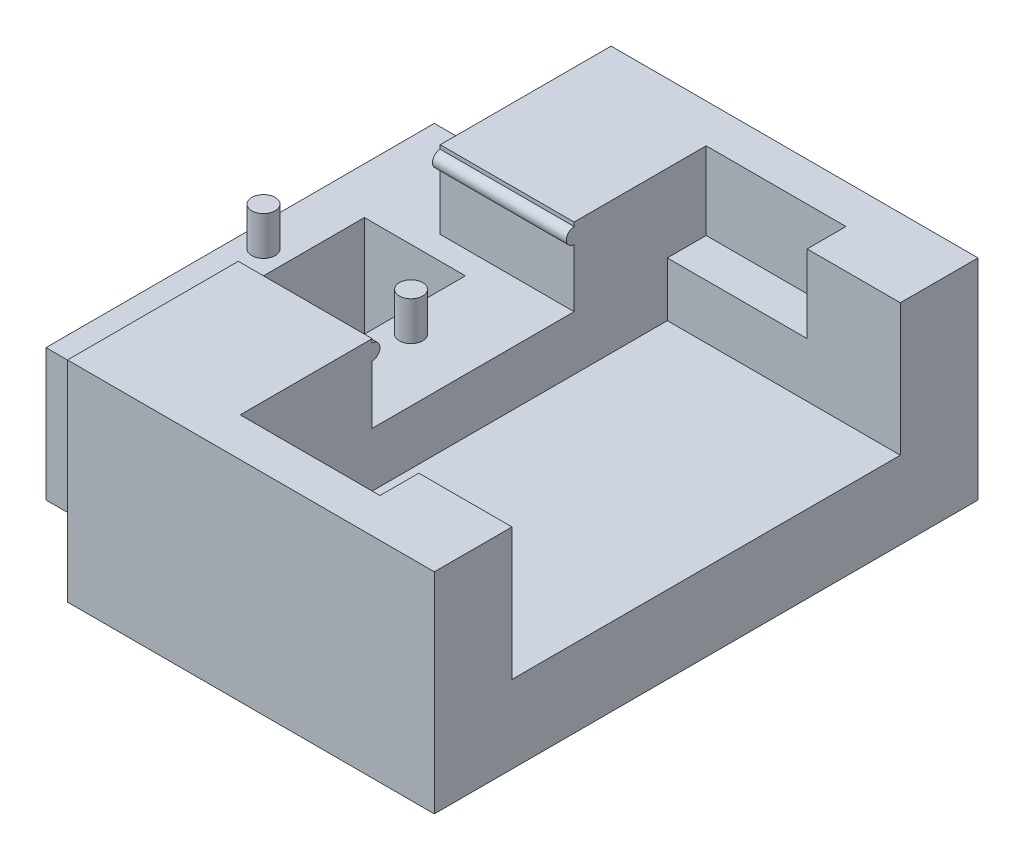
from build123d import *

# Parameters (mm, degrees)
SKETCH1_W             = 15.24
SKETCH1_H             = 12.7
MAIN_BASE_DEPTH       = 2.54
ALIGNMENTPINS_START   = 1.778
SKETCH2_R             = 0.381
ALIGNMENTPINS_DEPTH   = 1.27
ALIGNMENTPINS_2_DEPTH = 1.27
SKETCH7_W             = 7.62
SKETCH7_H             = 12.7
PCBOARDEDGES_DEPTH    = 1.778
SKETCH12_W            = 4.379010271
SKETCH12_H            = 3.048
CONNECTORALIGN_DEPTH  = 2.54
SKETCH13_W            = 3.302
SKETCH13_H            = 5.08
LEDHOLE_DEPTH         = 5.318
SKETCH14_W            = 11.999010271
SKETCH14_H            = 6.858
SHOULDER_DEPTH        = 2.54
SKETCH15_W            = 11.999010271
SKETCH15_H            = 6.858
SHOULDER2_DEPTH       = 2.54
PCB_CLIP_START        = -4.37901
SKETCH17_R            = 0.254
PCB_CLIP_DEPTH        = 4.37901
SKETCH18_W            = 4.572
SKETCH18_H            = 2.54
NUNCHUCKCLIP_DEPTH    = 1.27
SKETCH19_W            = 4.572
SKETCH19_H            = 2.54
NUNCHUCKCLIP2_DEPTH   = 1.27
CUT_EXTRUDE1_DEPTH    = 0.508


with BuildPart() as part:
    # Sketch1 → Main Base (new body)
    with BuildSketch(Plane(origin=(0, 0, 0), x_dir=(1, 0, 0), z_dir=(0, 1, 0))):
        with Locations((7.62, 6.35)):
            Rectangle(SKETCH1_W, SKETCH1_H)
    extrude(amount=MAIN_BASE_DEPTH)



with BuildPart() as body_2:
    # Sketch2 → AlignmentPins (new body)
    with BuildSketch(Plane(origin=(0, 2.54, 0), x_dir=(-1, 0, 0), z_dir=(0, 1, 0)).offset(ALIGNMENTPINS_START)):
        with Locations((-0.762, -6.35)):
            Circle(SKETCH2_R)
    extrude(amount=ALIGNMENTPINS_DEPTH)


with BuildPart() as body_3:
    # Sketch2 → AlignmentPins 2 (new body)
    with BuildSketch(Plane(origin=(0, 2.54, 0), x_dir=(-1, 0, 0), z_dir=(0, 1, 0)).offset(ALIGNMENTPINS_START)):
        with Locations((-5.588, -6.35)):
            Circle(SKETCH2_R)
    extrude(amount=ALIGNMENTPINS_2_DEPTH)


with BuildPart() as part_1:
    add(part.part)

    add(body_2.part)  # PCBoardEdges merges body 2

    add(body_3.part)  # PCBoardEdges merges body 3
    # Sketch7 → PCBoardEdges (add)
    with BuildSketch(Plane(origin=(0, 2.54, 0), x_dir=(1, 0, 0), z_dir=(0, 1, 0))):
        with Locations((3.81, 6.35)):
            Rectangle(SKETCH7_W, SKETCH7_H)
    extrude(amount=PCBOARDEDGES_DEPTH)

    # Sketch12 → ConnectorAlign (add)
    with BuildSketch(Plane(origin=(0, 4.318, 0), x_dir=(1, 0, 0), z_dir=(0, 1, 0))):
        with Locations((5.430494864, 1.524)):
            Rectangle(SKETCH12_W, SKETCH12_H)
        with Locations((5.430494864, 11.176)):
            Rectangle(SKETCH12_W, SKETCH12_H)
    extrude(amount=CONNECTORALIGN_DEPTH)

    # Sketch13 → LEDHole (cut, through all)
    with BuildSketch(Plane(origin=(0, 4.318, 0), x_dir=(1, 0, 0), z_dir=(0, 1, 0))):
        with Locations((3.175, 6.35)):
            Rectangle(SKETCH13_W, SKETCH13_H)
    extrude(amount=-LEDHOLE_DEPTH, mode=Mode.SUBTRACT)

    # Sketch14 → Shoulder (add)
    with BuildSketch(Plane.XY):
        with Locations((9.240494865, 3.429)):
            Rectangle(SKETCH14_W, SKETCH14_H)
    extrude(amount=SHOULDER_DEPTH)

    # Sketch15 → Shoulder2 (add)
    with BuildSketch(Plane(origin=(0, 0, -12.7), x_dir=(-1, 0, 0), z_dir=(0, 0, -1))):
        with Locations((-9.240494865, 3.429)):
            Rectangle(SKETCH15_W, SKETCH15_H)
    extrude(amount=SHOULDER2_DEPTH)

    # Sketch17 → PCB_Clip (add)
    with BuildSketch(Plane(origin=(7.62, 0, 0), x_dir=(0, 0, -1), z_dir=(1, 0, 0)).offset(PCB_CLIP_START)):
        with Locations((3.048, 6.477)):
            Circle(SKETCH17_R)
        with Locations((9.652, 6.477)):
            Circle(SKETCH17_R)
    extrude(amount=PCB_CLIP_DEPTH)

    # Sketch18 → NunchuckClip (cut)
    with BuildSketch(Plane(origin=(0, 0, 0), x_dir=(-1, 0, 0), z_dir=(0, 0, -1))):
        with Locations((-9.906, 5.588)):
            Rectangle(SKETCH18_W, SKETCH18_H)
    extrude(amount=-NUNCHUCKCLIP_DEPTH, mode=Mode.SUBTRACT)

    # Sketch19 → NunchuckClip2 (cut)
    with BuildSketch(Plane.XY.offset(-12.7)):
        with Locations((9.906, 5.588)):
            Rectangle(SKETCH19_W, SKETCH19_H)
    extrude(amount=-NUNCHUCKCLIP2_DEPTH, mode=Mode.SUBTRACT)

    # Sketch20 → Cut-Extrude1 (cut)
    with BuildSketch(Plane.XZ):
        Polygon((8.217257779, -3.407193662), (8.217257779, -5.712243662), (6.016982779, -5.712243662), (6.016982779, -0.892593662), (14.398982779, -0.892593662), (14.398982779, -5.712243662), (12.198707779, -5.712243662), (12.198707779, -3.407193662), (11.255732779, -3.407193662), (11.255732779, -5.083593662), (9.055457779, -5.083593662), (9.055457779, -3.407193662), align=None)
        with BuildLine():
            Line((14.398982779, -7.493418662), (14.398982779, -11.893968662))
            Line((14.398982779, -11.893968662), (12.932132779, -11.893968662))
            Line((12.932132779, -11.893968662), (12.932132779, -9.819751084))
            Line((12.932132779, -9.819751084), (11.781244888, -9.62002374))
            add(Edge.make_bspline(
                [(11.781244888, -9.62002374), (11.770251243, -9.701615614), (11.748663963, -9.861830588), (11.690486481, -10.092391141), (11.615599165, -10.308891021), (11.520125231, -10.50985122), (11.405471862, -10.695560634), (11.270958242, -10.865311588), (11.120486873, -11.022229739), (10.949196623, -11.16103415), (10.761135353, -11.283987594), (10.557944594, -11.392930954), (10.337872373, -11.481879106), (10.102990479, -11.555971833), (9.853586477, -11.614857534), (9.588035638, -11.655012226), (9.307512918, -11.680069087), (9.114994844, -11.682943238), (9.016167154, -11.684418662)],
                knots=[0, 0, 0, 0, 0.000246818, 0.000484656, 0.000711955, 0.000933104, 0.001150717, 0.001365234, 0.001581735, 0.001801627, 0.002025024, 0.00225499, 0.002492123, 0.002735986, 0.002993304, 0.003260037, 0.003541058, 0.003837488, 0.003837488, 0.003837488, 0.003837488], degree=3))
            add(Edge.make_bspline(
                [(9.016167154, -11.684418662), (8.905845682, -11.682210565), (8.68961718, -11.677882727), (8.372872854, -11.644171577), (8.070289394, -11.591506566), (7.783499686, -11.513120981), (7.50963283, -11.418624818), (7.253853676, -11.294705499), (7.009895928, -11.155322531), (6.785472567, -10.99155228), (6.581476114, -10.81250602), (6.401376691, -10.621361865), (6.251345496, -10.416180814), (6.127577636, -10.200488598), (6.029896075, -9.973283881), (5.961530212, -9.734567465), (5.918899529, -9.48458455), (5.914467439, -9.314058562), (5.912207779, -9.22711749)],
                knots=[0, 0, 0, 0, 0.000330895, 0.000648549, 0.000954583, 0.00125123, 0.001539645, 0.00182231, 0.002102538, 0.002381539, 0.002654132, 0.002915916, 0.003167717, 0.003414839, 0.003660542, 0.00390768, 0.004158249, 0.004418878, 0.004418878, 0.004418878, 0.004418878], degree=3))
            add(Edge.make_bspline(
                [(5.912207779, -9.22711749), (5.91445515, -9.141879038), (5.918894654, -8.973497236), (5.952975516, -8.724244798), (6.006861153, -8.48157511), (6.081680985, -8.244815631), (6.181740166, -8.016042881), (6.300749021, -7.793180228), (6.443204901, -7.577175879), (6.60469356, -7.3712837), (6.778629295, -7.179505186), (6.962203599, -7.01236275), (7.15024709, -6.869703261), (7.343165184, -6.752025997), (7.544148349, -6.663616031), (7.748263448, -6.596817328), (7.959336029, -6.558322833), (8.101419593, -6.553084662), (8.173055826, -6.550443662)],
                knots=[0, 0, 0, 0, 0.000255646, 0.000505008, 0.000753251, 0.00100073, 0.001248584, 0.001501277, 0.001757823, 0.002023741, 0.002285618, 0.002533617, 0.002767397, 0.002992849, 0.00320977, 0.003424631, 0.003635926, 0.003850787, 0.003850787, 0.003850787, 0.003850787], degree=3))
            add(Edge.make_bspline(
                [(8.173055826, -6.550443662), (8.185703613, -6.55112084), (8.209065854, -6.552371684), (8.21468206, -6.574619572), (8.217257779, -6.584822959)],
                knots=[0, 0, 0, 0, 3.375e-05, 6.2341e-05, 6.2341e-05, 6.2341e-05, 6.2341e-05], degree=3))
            add(Edge.make_bspline(
                [(8.217257779, -6.584822959), (8.21379986, -6.598956726), (8.204910316, -6.635291506), (8.178023964, -6.661887625), (8.16159606, -6.678138193)],
                knots=[0, 0, 0, 0, 4.2972e-05, 0.000110472, 0.000110472, 0.000110472, 0.000110472], degree=3))
            add(Edge.make_bspline(
                [(8.16159606, -6.678138193), (8.136365772, -6.700405265), (8.077016572, -6.752784095), (7.993692338, -6.862131275), (7.902122779, -7.009388757), (7.800385555, -7.184339204), (7.708056874, -7.377085557), (7.639849213, -7.574659381), (7.596386201, -7.767637982), (7.591153517, -7.895938561), (7.588607779, -7.958357724)],
                knots=[0, 0, 0, 0, 0.000100772, 0.000237046, 0.000410069, 0.00062125, 0.000843879, 0.001049934, 0.0012474, 0.00143449, 0.00143449, 0.00143449, 0.00143449], degree=3))
            add(Edge.make_bspline(
                [(7.588607779, -7.958357724), (7.589364169, -8.003161205), (7.590845457, -8.090902724), (7.607861397, -8.218508769), (7.633961608, -8.339043342), (7.670022293, -8.453352628), (7.717335918, -8.560860294), (7.774738157, -8.661469601), (7.843243248, -8.754458019), (7.920801372, -8.840377114), (8.008056037, -8.917894183), (8.103416935, -8.984707761), (8.204925166, -9.042944891), (8.314460725, -9.087724989), (8.428623769, -9.127224479), (8.551689353, -9.149790175), (8.680576304, -9.167789672), (8.76943719, -9.169132909), (8.814802701, -9.169818662)],
                knots=[0, 0, 0, 0, 0.000134333, 0.000263072, 0.000385418, 0.000503982, 0.000622001, 0.000737136, 0.000850758, 0.00096782, 0.00108379, 0.001200071, 0.001316628, 0.001433998, 0.001554623, 0.001678233, 0.001808597, 0.001944566, 0.001944566, 0.001944566, 0.001944566], degree=3))
            add(Edge.make_bspline(
                [(8.814802701, -9.169818662), (8.855799497, -9.169091152), (8.935958333, -9.16766869), (9.052576868, -9.150249952), (9.16328584, -9.125037681), (9.265814181, -9.086505827), (9.363252497, -9.041250504), (9.451262049, -8.981147756), (9.533643551, -8.912152178), (9.609276284, -8.833428845), (9.67666913, -8.744332428), (9.73502713, -8.646476727), (9.785210532, -8.540365748), (9.823615634, -8.425214765), (9.85492271, -8.301566212), (9.87766612, -8.169699968), (9.890636219, -8.029012368), (9.892629227, -7.932736654), (9.893657779, -7.883050693)],
                knots=[0, 0, 0, 0, 0.000122881, 0.000240263, 0.000353034, 0.00046283, 0.000568268, 0.000674516, 0.000781419, 0.000890259, 0.001001257, 0.001115807, 0.001231522, 0.001352668, 0.00147933, 0.001613902, 0.001753672, 0.001902729, 0.001902729, 0.001902729, 0.001902729], degree=3))
            add(Edge.make_bspline(
                [(9.893657779, -7.883050693), (9.892472166, -7.825689716), (9.890150122, -7.713347192), (9.869778513, -7.548529099), (9.837864771, -7.391618982), (9.791184949, -7.242714697), (9.733050352, -7.101808236), (9.65950445, -6.969728078), (9.575093218, -6.844330987), (9.508174474, -6.768579517), (9.474557779, -6.730525693)],
                knots=[0, 0, 0, 0, 0.000172021, 0.000336907, 0.000497444, 0.000651749, 0.000804378, 0.000953849, 0.001104606, 0.001256786, 0.001256786, 0.001256786, 0.001256786], degree=3))
            Line((9.474557779, -6.730525693), (9.536767935, -6.655218662))
            Line((9.536767935, -6.655218662), (14.398982779, -7.493418662))
        make_face()
    extrude(amount=-CUT_EXTRUDE1_DEPTH, mode=Mode.SUBTRACT)


solid = part_1.part
